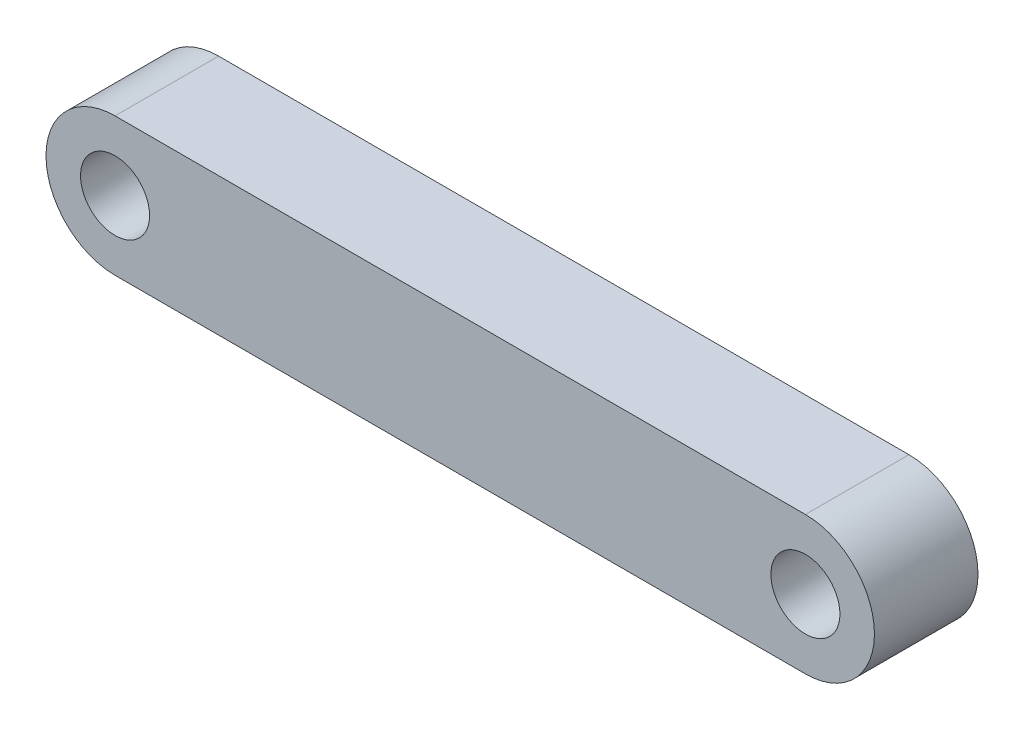
from build123d import *

# Parameters (mm, degrees)
EXTRUDE_1_DEPTH = 15


with BuildPart() as part:
    # 草图1 → 凸台-拉伸1 (new body)
    with BuildSketch(Plane.XY):
        with BuildLine():
            Line((100, 0), (0, 0))
            ThreePointArc((0, 0), (7.071067812, -2.928932188), (10, -10))
            ThreePointArc((10, -10), (7.071067812, -17.071067812), (0, -20))
            Line((0, -20), (100, -20))
            ThreePointArc((100, -20), (90, -10), (100, 0))
        make_face()
        with BuildLine():
            ThreePointArc((10, -10), (7.071067812, -2.928932188), (0, 0))
            Line((0, 0), (0, -5))
            ThreePointArc((0, -5), (3.535533906, -6.464466094), (5, -10))
            ThreePointArc((5, -10), (3.535533906, -13.535533906), (0, -15))
            Line((0, -15), (0, -20))
            ThreePointArc((0, -20), (7.071067812, -17.071067812), (10, -10))
        make_face()
        with BuildLine():
            Line((0, -5), (0, 0))
            ThreePointArc((0, 0), (-10, -10), (0, -20))
            Line((0, -20), (0, -15))
            ThreePointArc((0, -15), (-5, -10), (0, -5))
        make_face()
        with BuildLine():
            ThreePointArc((110, -10), (107.071067812, -2.928932188), (100, 0))
            Line((100, 0), (100, -5))
            ThreePointArc((100, -5), (103.535533906, -6.464466094), (105, -10))
            ThreePointArc((105, -10), (103.535533906, -13.535533906), (100, -15))
            Line((100, -15), (100, -20))
            ThreePointArc((100, -20), (107.071067812, -17.071067812), (110, -10))
        make_face()
        with BuildLine():
            Line((100, -5), (100, 0))
            ThreePointArc((100, 0), (90, -10), (100, -20))
            Line((100, -20), (100, -15))
            ThreePointArc((100, -15), (95, -10), (100, -5))
        make_face()
    extrude(amount=EXTRUDE_1_DEPTH)


solid = part.part
